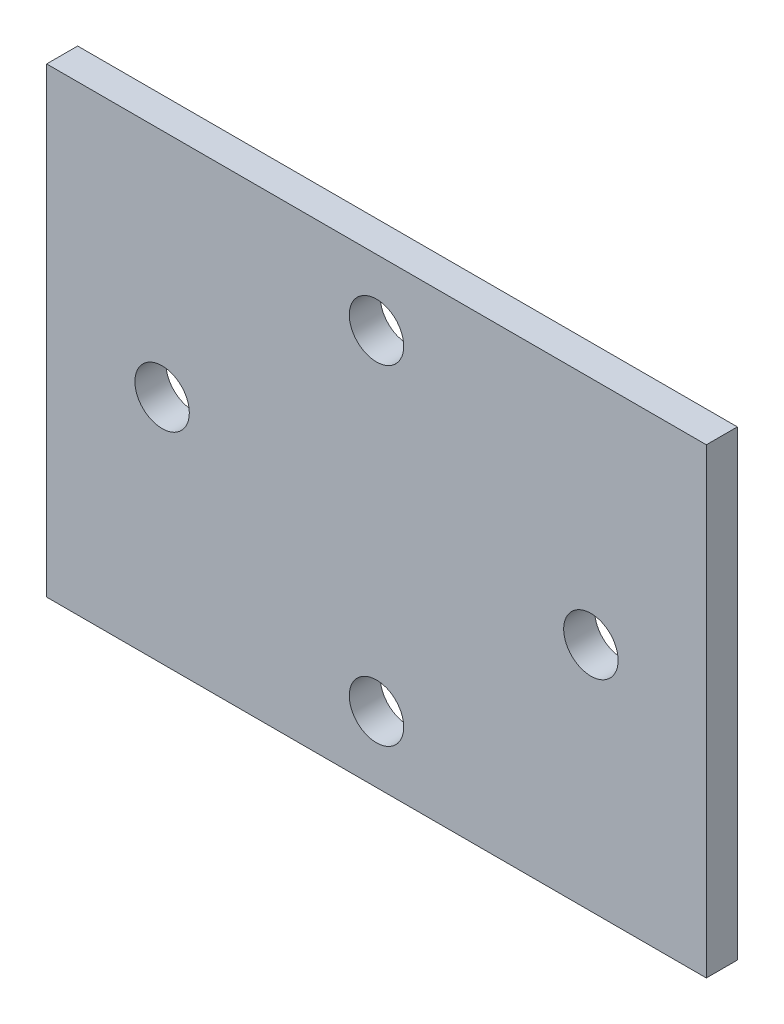
from build123d import *

# Parameters (mm, degrees)
BOSS_EXTRUDE1_DEPTH      = 2.3876
BOSS_EXTRUDE1_DEPTH_BACK = 2.3876
SKETCH4_R                = 3.2639
CUT_EXTRUDE1_DEPTH       = 5.7752
SKETCH7_W                = 101.6
SKETCH7_H                = 101.6
BOSS_EXTRUDE2_DEPTH      = 4.7752
SKETCH10_R               = 4.191
CUT_EXTRUDE3_DEPTH       = 5.7752
SKETCH11_OUTSIDE_W       = 132.352
SKETCH11_OUTSIDE_H       = 132.352
SKETCH11_OUTSIDE_W_2     = 101.6
SKETCH11_OUTSIDE_H_2     = 71.12
CUT_EXTRUDE4_DEPTH       = 4.7752


with BuildPart() as part:
    # Sketch3 → Boss-Extrude1 (new body, two sides)
    with BuildSketch(Plane.XY) as boss_extrude1_sk:
        Polygon((50.8, -25.4), (50.8, -50.8), (-50.8, -50.8), (-50.8, 50.8), (-25.4, 50.8), align=None)
    extrude(amount=BOSS_EXTRUDE1_DEPTH)
    extrude(boss_extrude1_sk.sketch, amount=-BOSS_EXTRUDE1_DEPTH_BACK)

    # Sketch4 → Cut-Extrude1 (cut, through all)
    with BuildSketch(Plane.XY.offset(2.3876)):
        with Locations((-38.1, -38.1)):
            Circle(SKETCH4_R)
        with Locations((-12.7, -38.1)):
            Circle(SKETCH4_R)
        with Locations((12.7, -38.1)):
            Circle(SKETCH4_R)
        with Locations((-38.1, -12.7)):
            Circle(SKETCH4_R)
        with Locations((-38.1, 12.7)):
            Circle(SKETCH4_R)
        with Locations((38.1, -38.1)):
            Circle(SKETCH4_R)
        with Locations((-38.1, 38.1)):
            Circle(SKETCH4_R)
    extrude(amount=-CUT_EXTRUDE1_DEPTH, mode=Mode.SUBTRACT)

    # Sketch7 → Boss-Extrude2 (add)
    with BuildSketch(Plane.XY.offset(2.3876)):
        Rectangle(SKETCH7_W, SKETCH7_H)
    extrude(amount=-BOSS_EXTRUDE2_DEPTH)

    # Sketch10 → Cut-Extrude3 (cut, through all)
    with BuildSketch(Plane.XY.offset(2.3876)):
        with Locations((-33.02, 0)):
            Circle(SKETCH10_R)
        with Locations((33.02, 0)):
            Circle(SKETCH10_R)
        with Locations((0, 25.4)):
            Circle(SKETCH10_R)
        with Locations((0, -25.4)):
            Circle(SKETCH10_R)
    extrude(amount=-CUT_EXTRUDE3_DEPTH, mode=Mode.SUBTRACT)

    # Sketch11 outside → Cut-Extrude4 (cut)
    with BuildSketch(Plane.XY.offset(2.3876)):
        Rectangle(SKETCH11_OUTSIDE_W, SKETCH11_OUTSIDE_H)
        Rectangle(SKETCH11_OUTSIDE_W_2, SKETCH11_OUTSIDE_H_2, mode=Mode.SUBTRACT)
    extrude(amount=-CUT_EXTRUDE4_DEPTH, mode=Mode.SUBTRACT)


solid = part.part
